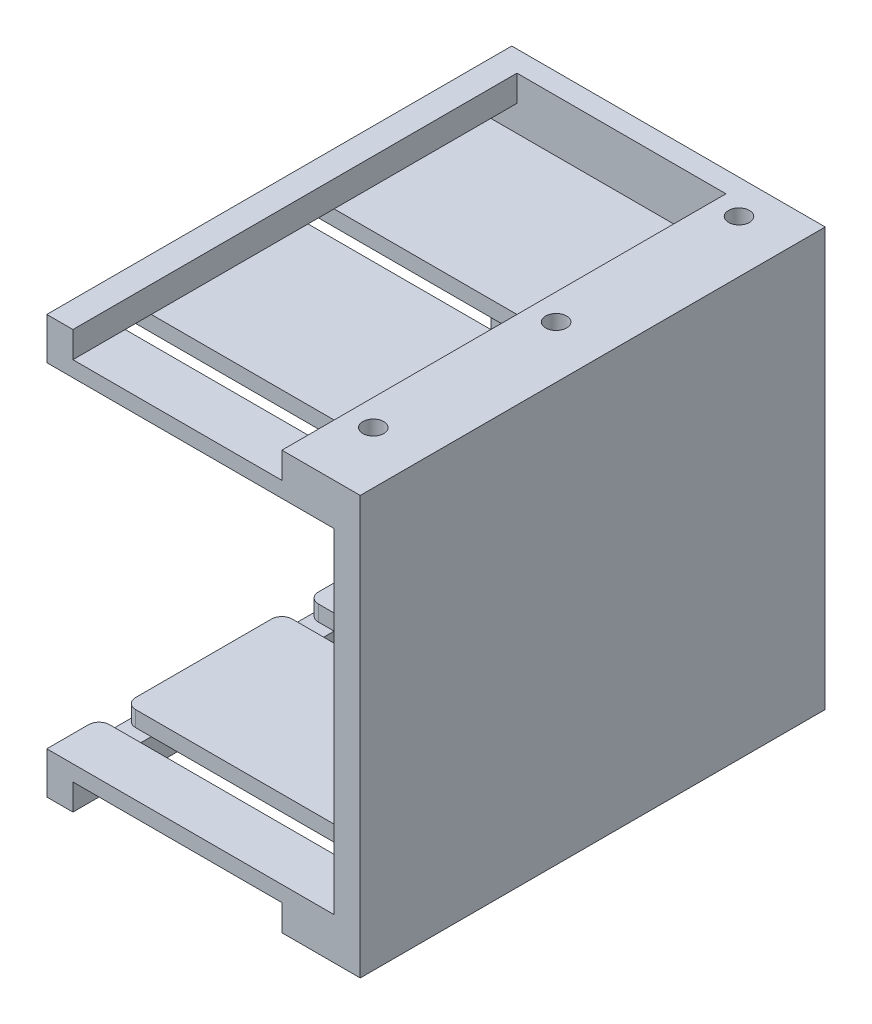
from build123d import *

# Parameters (mm, degrees)
SKETCH1_W           = 80
SKETCH1_H           = 60
BOSS_EXTRUDE1_DEPTH = 4
SKETCH3_W           = 5
SKETCH3_H           = 5
BOSS_EXTRUDE2_DEPTH = 85
SKETCH9_W           = 3
SKETCH9_H           = 30
SKETCH9_H_2         = 10
BOSS_EXTRUDE4_DEPTH = 55
FILLET2_R           = 2
SKETCH11_R          = 2
CUT_EXTRUDE2_DEPTH  = 4.5


with BuildPart() as part:
    # Sketch1 → Boss-Extrude1 (new body)
    with BuildSketch(Plane(origin=(0, 0, 0), x_dir=(0, 1, 0), z_dir=(0, 0, 1))):
        with Locations((-40, -30)):
            Rectangle(SKETCH1_W, SKETCH1_H)
    extrude(amount=BOSS_EXTRUDE1_DEPTH)

    # Sketch3 → Boss-Extrude2 (add)
    with BuildSketch(Plane.XY.offset(4)):
        with Locations((2.5, -2.5)):
            Rectangle(SKETCH3_W, SKETCH3_H)
        with Locations((2.5, -77.5)):
            Rectangle(SKETCH3_W, SKETCH3_H)
        Polygon((60, 0), (55, 0), (45, 0), (45, -5), (55, -5), (55, -75), (45, -75), (45, -80), (52.705337411, -80), (60, -80), align=None)
    extrude(amount=BOSS_EXTRUDE2_DEPTH)

    # Sketch9 → Boss-Extrude4 (add)
    with BuildSketch(Plane(origin=(55, 0, 0), x_dir=(0, -1, 0), z_dir=(-1, 0, 0))):
        with Locations((6.5, 24)):
            Rectangle(SKETCH9_W, SKETCH9_H)
        with Locations((6.5, 59)):
            Rectangle(SKETCH9_W, SKETCH9_H)
        with Locations((6.5, 84)):
            Rectangle(SKETCH9_W, SKETCH9_H_2)
        with Locations((73.5, 24)):
            Rectangle(SKETCH9_W, SKETCH9_H)
        with Locations((73.5, 59)):
            Rectangle(SKETCH9_W, SKETCH9_H)
        with Locations((73.5, 84)):
            Rectangle(SKETCH9_W, SKETCH9_H_2)
    extrude(amount=BOSS_EXTRUDE4_DEPTH)

    # Fillet2
    fillet2_edges = [part.edges().sort_by_distance(p)[0] for p in [
        (0, -6.5, 79),
        (0, -73.5, 39),
        (0, -73.5, 9),
        (0, -73.5, 74),
        (0, -73.5, 44),
        (0, -73.5, 79),
        (0, -6.5, 9),
        (0, -6.5, 39),
        (0, -6.5, 44),
        (0, -6.5, 74),
    ]]
    fillet(fillet2_edges, radius=FILLET2_R)

    # Sketch11 → Cut-Extrude2 (cut)
    with BuildSketch(Plane(origin=(0, 0, 0), x_dir=(-1, 0, 0), z_dir=(0, 1, 0))):
        with Locations((-50, 76.5)):
            Circle(SKETCH11_R)
        with Locations((-50, 41.5)):
            Circle(SKETCH11_R)
        with Locations((-50, 6.5)):
            Circle(SKETCH11_R)
    extrude(amount=-CUT_EXTRUDE2_DEPTH, mode=Mode.SUBTRACT)


solid = part.part
